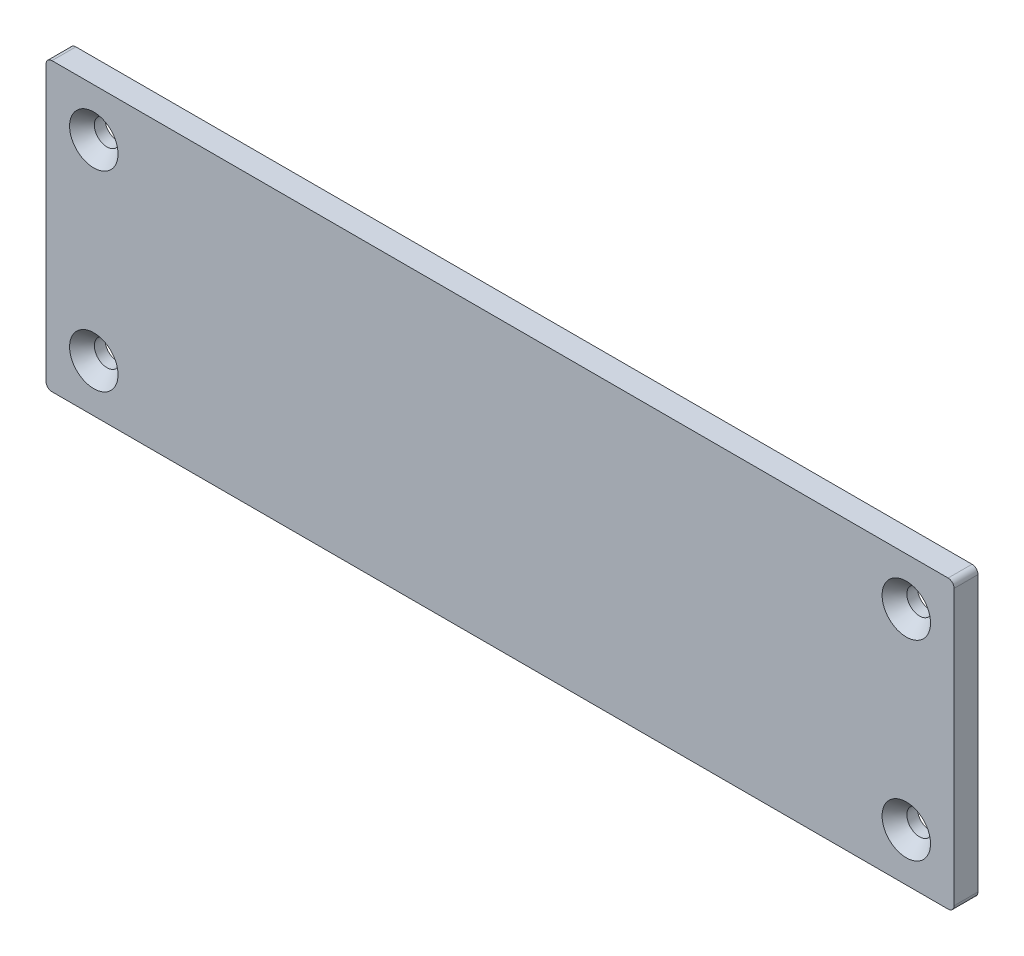
from build123d import *

# Parameters (mm, degrees)
SKETCH1_W                                   = 241.3
SKETCH1_H                                   = 76.2
BOSS_EXTRUDE1_DEPTH                         = 6.35
CSK_FOR_1_4_FLAT_HEAD_MACHINE_SCREW_2_COUNT = 2
CSK_FOR_1_4_FLAT_HEAD_MACHINE_SCREW_2_PITCH = 50.8
CSK_FOR_1_4_FLAT_HEAD_MACHINE_SCREW_3_COUNT = 2
CSK_FOR_1_4_FLAT_HEAD_MACHINE_SCREW_3_PITCH = 215.9
CSK_FOR_1_4_FLAT_HEAD_MACHINE_SCREW_4_COUNT = 2
CSK_FOR_1_4_FLAT_HEAD_MACHINE_SCREW_4_PITCH = 221.795964796
FILLET1_R                                   = 1.5875


with BuildPart() as part:
    # Sketch1 → Boss-Extrude1 (new body)
    with BuildSketch(Plane.XY):
        Rectangle(SKETCH1_W, SKETCH1_H)
    extrude(amount=BOSS_EXTRUDE1_DEPTH)

    # Sketch4 → CSK for 1/4 Flat Head Machine Screw (100)1 (revolve, cut)
    with BuildSketch(Plane(origin=(107.95, 25.4, 6.35), x_dir=(0, -1, 0), z_dir=(1, 0, 0))):
        Polygon((0, 0), (0, 6.35), (3.3782, 6.35), (3.3782, 3.520932584), (6.4389, 0), align=None)
    csk_for_1_4_flat_head_machine_screw_100 = revolve(axis=Axis((107.95, 25.4, 12.7), (0, 0, -1)), mode=Mode.SUBTRACT)

    # CSK for 1_4 Flat Head Machine Screw  2: CSK for 1/4 Flat Head Machine Screw (100)1 ×2
    with Locations(*[(0, -i * CSK_FOR_1_4_FLAT_HEAD_MACHINE_SCREW_2_PITCH, 0) for i in range(1, CSK_FOR_1_4_FLAT_HEAD_MACHINE_SCREW_2_COUNT)]):
        add(csk_for_1_4_flat_head_machine_screw_100, mode=Mode.SUBTRACT)

    # CSK for 1_4 Flat Head Machine Screw  3: CSK for 1/4 Flat Head Machine Screw (100)1 ×2
    with Locations(*[(-i * CSK_FOR_1_4_FLAT_HEAD_MACHINE_SCREW_3_PITCH, 0, 0) for i in range(1, CSK_FOR_1_4_FLAT_HEAD_MACHINE_SCREW_3_COUNT)]):
        add(csk_for_1_4_flat_head_machine_screw_100, mode=Mode.SUBTRACT)

    # CSK for 1_4 Flat Head Machine Screw  4: CSK for 1/4 Flat Head Machine Screw (100)1 ×2
    with Locations(*[Vector(-0.973417168, -0.229039334, 0) * (i * CSK_FOR_1_4_FLAT_HEAD_MACHINE_SCREW_4_PITCH) for i in range(1, CSK_FOR_1_4_FLAT_HEAD_MACHINE_SCREW_4_COUNT)]):
        add(csk_for_1_4_flat_head_machine_screw_100, mode=Mode.SUBTRACT)

    # Fillet1
    fillet1_edges = [part.edges().sort_by_distance(p)[0] for p in [
        (120.65, -38.1, 3.175),
        (-120.65, -38.1, 3.175),
        (-120.65, 38.1, 3.175),
        (120.65, 38.1, 3.175),
    ]]
    fillet(fillet1_edges, radius=FILLET1_R)


solid = part.part
